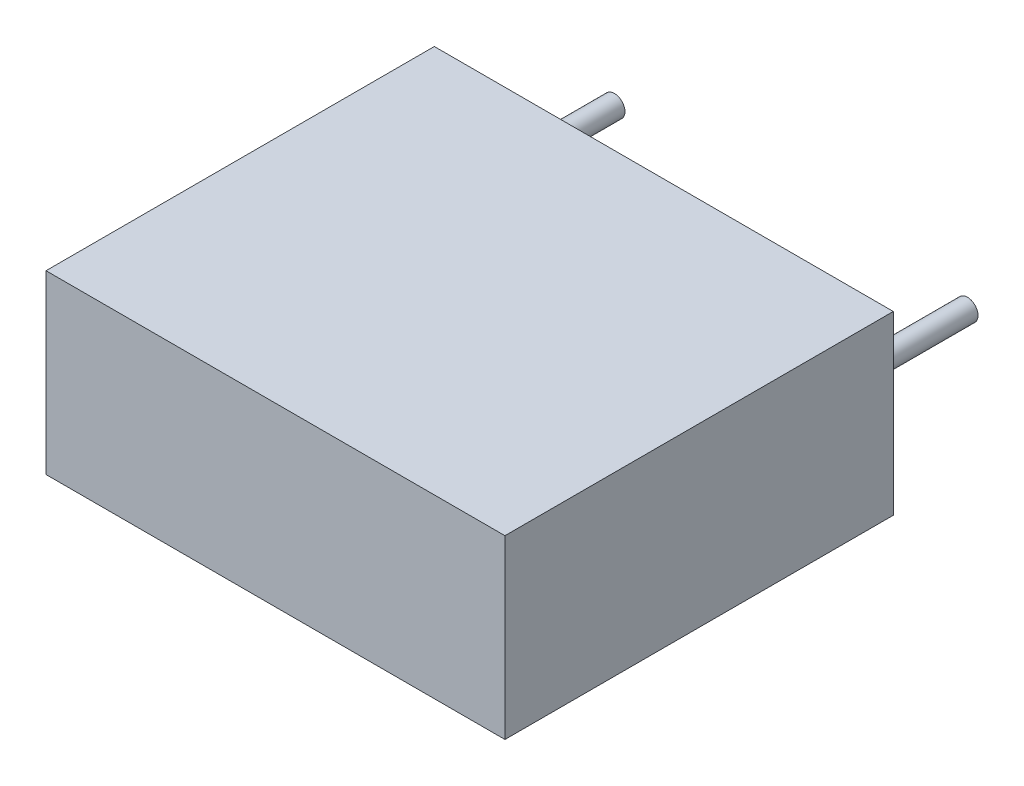
from build123d import *

# Parameters (mm, degrees)
ESQUISSE1_W        = 13
ESQUISSE1_H        = 5
BOSS_EXTRU_1_DEPTH = 11
ESQUISSE2_R        = 0.3
BOSS_EXTRU_2_DEPTH = 3.6


with BuildPart() as part:
    # Esquisse1 → Boss.-Extru.1 (new body)
    with BuildSketch(Plane.XY):
        Rectangle(ESQUISSE1_W, ESQUISSE1_H)
    extrude(amount=BOSS_EXTRU_1_DEPTH)

    # Esquisse2 → Boss.-Extru.2 (add)
    with BuildSketch(Plane(origin=(0, 0, 0), x_dir=(-1, 0, 0), z_dir=(0, 0, -1))):
        with Locations((-5, 0)):
            Circle(ESQUISSE2_R)
        with Locations((5, 0)):
            Circle(ESQUISSE2_R)
    extrude(amount=BOSS_EXTRU_2_DEPTH)


solid = part.part
